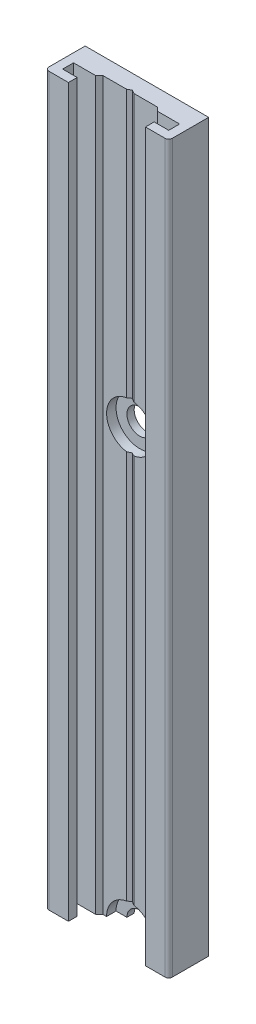
from build123d import *

# Parameters (mm, degrees)
BOSS_EXTRUDE1_DEPTH = 100
CUT_EXTRUDE1_DEPTH  = 101
DRAFT1_ANGLE        = 45
DRAFT2_ANGLE        = 45
DRAFT3_ANGLE        = 60.000000395


with BuildPart() as part:
    # Sketch1 → Boss-Extrude1 (new body)
    with BuildSketch(Plane(origin=(0, 100, 0), x_dir=(1, 0, 0), z_dir=(0, 1, 0))):
        with BuildLine():
            Line((-8, -5.5), (8, -5.5))
            ThreePointArc((8, -5.5), (8.353553391, -5.353553391), (8.5, -5))
            Line((8.5, -5), (8.5, 0))
            Line((8.5, 0), (-8.5, 0))
            Line((-8.5, 0), (-8.5, -5))
            ThreePointArc((-8.5, -5), (-8.353553391, -5.353553391), (-8, -5.5))
        make_face()
    extrude(amount=-BOSS_EXTRUDE1_DEPTH)

    # Sketch2 → Cut-Extrude1 (cut, through all)
    with BuildSketch(Plane.XZ):
        Polygon((5.3, 5.5), (-5.3, 5.5), (-5.3, 4.3), (-7.3, 4.3), (-7.3, 2.8), (-3.75, 2.8), (-3.75, 2.3), (-0.5, 2.3), (0.499999996, 1.722649733), (0.499999996, 2.3), (3.75, 2.3), (3.75, 2.8), (7.3, 2.8), (7.3, 4.3), (5.3, 4.3), align=None)
    extrude(amount=-CUT_EXTRUDE1_DEPTH, mode=Mode.SUBTRACT)

    # Draft1
    draft1_faces = [part.faces().sort_by_distance(p)[0] for p in [
        (-3.75, 50, 2.55),
    ]]
    draft(draft1_faces, Plane(origin=(-3.75, 100, 2.3), x_dir=(1, 0, 0), z_dir=(0, 0, 1)), DRAFT1_ANGLE)

    # Draft2
    draft2_faces = [part.faces().sort_by_distance(p)[0] for p in [
        (3.75, 50, 2.55),
    ]]
    draft(draft2_faces, Plane(origin=(0.499999996, 100, 2.3), x_dir=(1, 0, 0), z_dir=(0, 0, 1)), DRAFT2_ANGLE)

    # Draft3
    draft3_faces = [part.faces().sort_by_distance(p)[0] for p in [
        (0.499999996, 50, 2.011324867),
    ]]
    draft(draft3_faces, Plane(origin=(0.499999996, 100, 2.3), x_dir=(1, 0, 0), z_dir=(0, 0, 1)), DRAFT3_ANGLE)

    # Sketch4 → Cut-Revolve2 (revolve, cut)
    with BuildSketch(Plane(origin=(0, 0, 0), x_dir=(1, 0, 0), z_dir=(0, 1, 0))):
        Polygon((1.75, 0), (0, 0), (0, -2.3), (3.25, -2.3), (3.25, -1), (1.75, -1), align=None)
    revolve(axis=Axis((0, 0, 0), (0, 0, 1)), mode=Mode.SUBTRACT)

    # Sketch5 → Cut-Revolve3 (revolve, cut)
    with BuildSketch(Plane(origin=(0, 60, 0), x_dir=(1, 0, 0), z_dir=(0, 1, 0))):
        Polygon((1.75, 0), (0, 0), (0, -2.3), (3.25, -2.3), (3.25, -1), (1.75, -1), align=None)
    revolve(axis=Axis((0, 60, 0), (0, 0, 1)), mode=Mode.SUBTRACT)


solid = part.part
